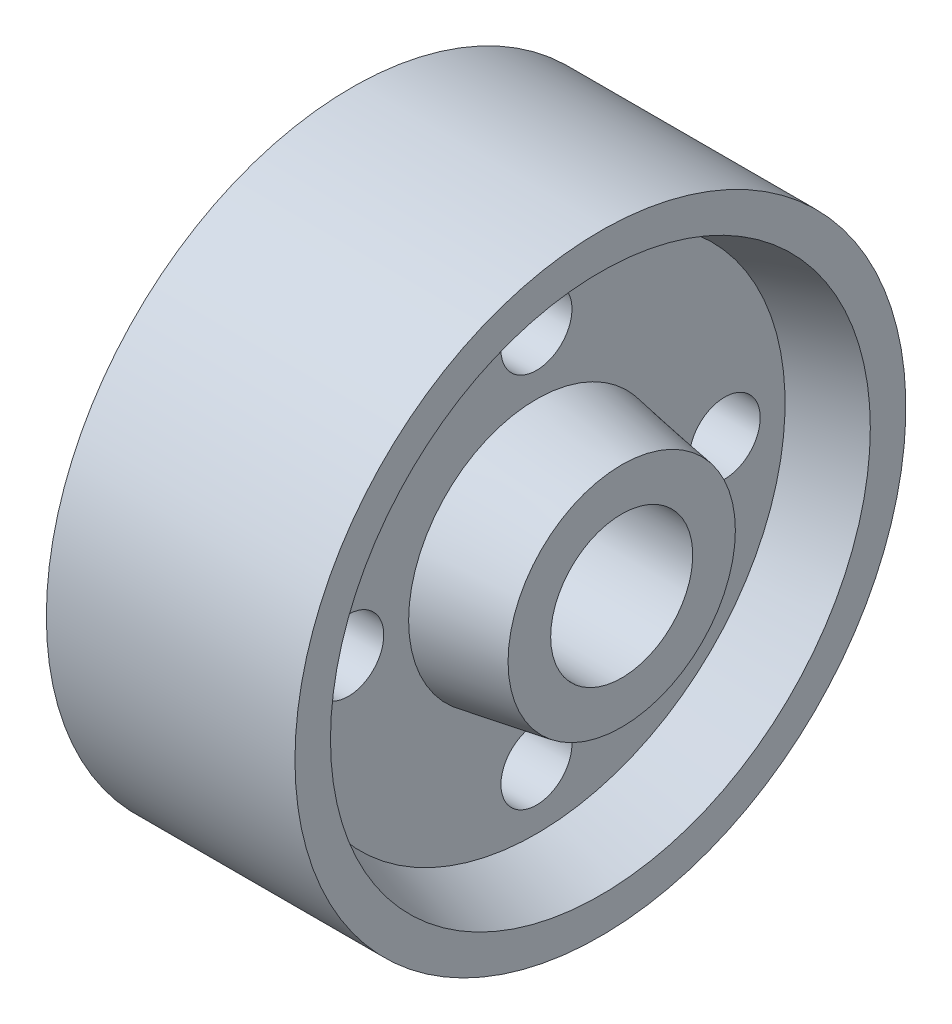
from build123d import *

# Parameters (mm, degrees)
SKETCH2_R          = 10
SKETCH2_R_2        = 5
CUT_EXTRUDE1_DEPTH = 42


with BuildPart() as part:
    # Sketch1 → Revolve1 (revolve)
    with BuildSketch(Plane.XY):
        Polygon((0, 0), (0, 16), (12, 18), (12, 35), (3, 38), (3, 43), (38, 43), (38, 38), (29, 35), (29, 18), (41, 16), (41, 0), align=None)
    revolve(axis=Axis((0, 0, 0), (1, 0, 0)))

    # Sketch2 → Cut-Extrude1 (cut, through all)
    with BuildSketch(Plane.ZY):
        Circle(SKETCH2_R)
        with Locations((0, 26.5)):
            Circle(SKETCH2_R_2)
        with Locations((26.5, 0)):
            Circle(SKETCH2_R_2)
        with Locations((0, -26.5)):
            Circle(SKETCH2_R_2)
        with Locations((-26.5, 0)):
            Circle(SKETCH2_R_2)
    extrude(amount=-CUT_EXTRUDE1_DEPTH, mode=Mode.SUBTRACT)


solid = part.part
